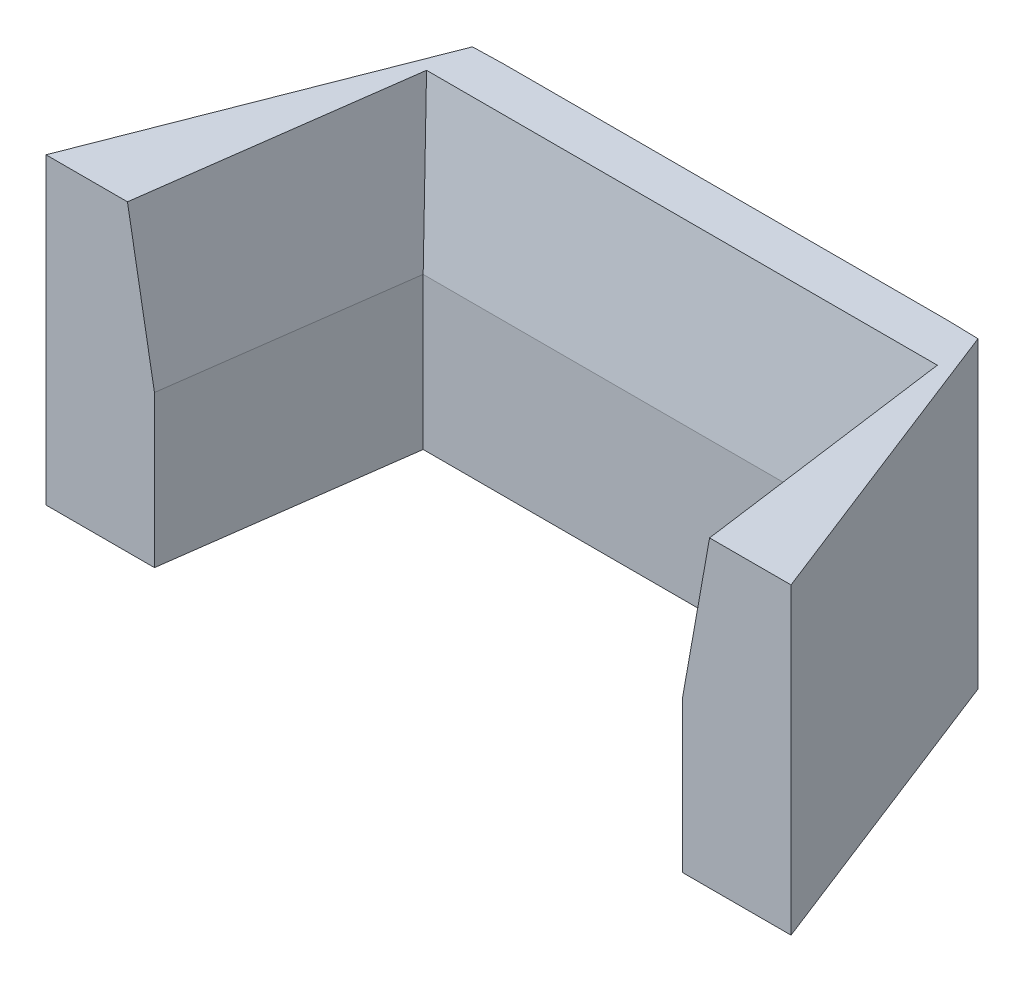
from build123d import *

# Parameters (mm, degrees)
SALIENTE_EXTRUIR1_DEPTH = 30
CORTAR_EXTRUIR2_DEPTH   = 90
CROQUIS5_W              = 20
CROQUIS5_H              = 2
SALIENTE_EXTRUIR2_DEPTH = 3
CHAFL_N1_SIZE           = 15
CHAFL_N1_SIZE2          = 2.644904711
CHAFL_N1_PART_2_SIZE    = 15
CHAFL_N1_PART_2_SIZE2   = 2.644904711
CHAFL_N1_PART_3_SIZE    = 15
CHAFL_N1_PART_3_SIZE2   = 2.644904711


with BuildPart() as part:
    # Croquis2 → Saliente-Extruir1 (new body)
    with BuildSketch(Plane(origin=(0, 0, 0), x_dir=(1, 0, 0), z_dir=(0, 1, 0))):
        Polygon((4.793050572, 35.408576274), (1.793050572, 35.33296049), (-12, 0), (0, 0), (3.845501771, 28.408576274), align=None)
        Polygon((48.793050572, 35.408576274), (4.793050572, 35.408576274), (3.845501771, 28.408576274), (49.740599373, 28.408576274), align=None)
        Polygon((51.793050572, 35.33296049), (48.793050572, 35.408576274), (49.740599373, 28.408576274), (53.586101144, 0), (65.586101144, 0), align=None)
    extrude(amount=SALIENTE_EXTRUIR1_DEPTH)

    # Croquis4 → Cortar-Extruir2 (cut, symmetric)
    with BuildSketch(Plane(origin=(0, 0, 0), x_dir=(0, 0, -1), z_dir=(1, 0, 0))):
        Polygon((0, 0), (5, 0), (5, 30), (-4.90661078, 30), (-4.90661078, 0), align=None)
    extrude(amount=CORTAR_EXTRUIR2_DEPTH, both=True, mode=Mode.SUBTRACT)

    # Croquis5 → Saliente-Extruir2 (add)
    with BuildSketch(Plane(origin=(0, 0, 0), x_dir=(-1, 0, 0), z_dir=(0, -1, 0))):
        with Locations((-26.793050572, 32.408576274)):
            Rectangle(CROQUIS5_W, CROQUIS5_H)
    extrude(amount=SALIENTE_EXTRUIR2_DEPTH)

    # Chaflán1
    chafl_n1_edges = [part.edges().sort_by_distance(p)[0] for p in [
        (26.793050572, 30, -28.408576274),
    ]]
    chafl_n1_side = [part.faces().sort_by_distance(p)[0] for p in [
        (26.793050572, 15, -28.408576274),
    ]]
    chamfer(chafl_n1_edges, length=CHAFL_N1_SIZE, length2=CHAFL_N1_SIZE2, reference=chafl_n1_side[0])

    # Chaflán1 part 2
    chafl_n1_part_2_edges = [part.edges().sort_by_distance(p)[0] for p in [
        (2.261161172, 30, -16.704288137),
    ]]
    chafl_n1_part_2_side = [part.faces().sort_by_distance(p)[0] for p in [
        (2.261161172, 15, -16.704288137),
    ]]
    chamfer(chafl_n1_part_2_edges, length=CHAFL_N1_PART_2_SIZE, length2=CHAFL_N1_PART_2_SIZE2, reference=chafl_n1_part_2_side[0])

    # Chaflán1 part 3
    chafl_n1_part_3_edges = [part.edges().sort_by_distance(p)[0] for p in [
        (51.324939972, 30, -16.704288137),
    ]]
    chafl_n1_part_3_side = [part.faces().sort_by_distance(p)[0] for p in [
        (51.324939972, 15, -16.704288137),
    ]]
    chamfer(chafl_n1_part_3_edges, length=CHAFL_N1_PART_3_SIZE, length2=CHAFL_N1_PART_3_SIZE2, reference=chafl_n1_part_3_side[0])


solid = part.part
